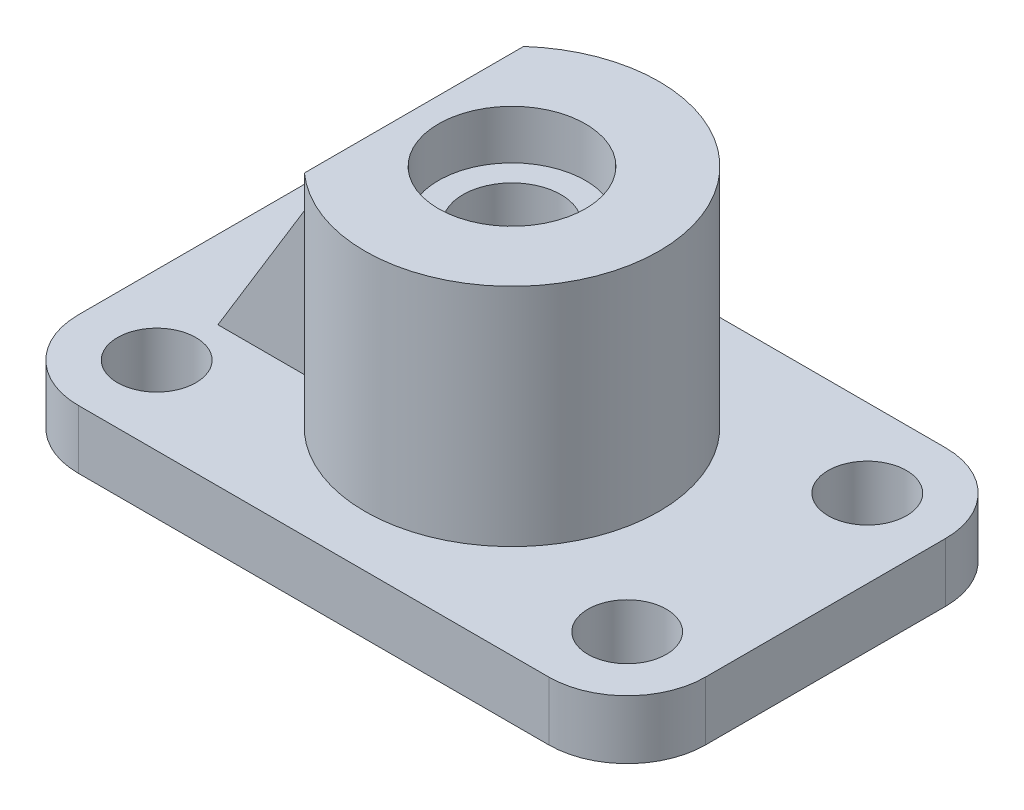
from build123d import *

# Parameters (mm, degrees)
IZIM1_R                     = 8
Y_KSEKLIK_EKSTR_ZYON1_DEPTH = 12
Y_KSEKLIK_EKSTR_ZYON2_DEPTH = 46
IZIM4_R                     = 15
KES_EKSTR_ZYON1_DEPTH       = 10
IZIM5_R                     = 10
KES_EKSTR_ZYON2_DEPTH       = 114.846387734
FEDER7_REACH                = 101.057
IZIM16_WALL_W               = 253.965251844
IZIM16_WALL_H               = 8


with BuildPart() as part:
    # Çizim1 → Yükseklik-Ekstrüzyon1 (new body)
    with BuildSketch(Plane(origin=(0, 0, 0), x_dir=(1, 0, 0), z_dir=(0, 1, 0))):
        with BuildLine():
            Line((48, 0), (-48, 0))
            ThreePointArc((-48, 0), (-59.313708499, 4.686291501), (-64, 16))
            Line((-64, 16), (-64, 49))
            Line((-64, 49), (-64, 65))
            ThreePointArc((-64, 65), (-59.313708499, 76.313708499), (-48, 81))
            Line((-48, 81), (48, 81))
            ThreePointArc((48, 81), (59.313708499, 76.313708499), (64, 65))
            Line((64, 65), (64, 49))
            Line((64, 49), (64, 16))
            ThreePointArc((64, 16), (59.313708499, 4.686291501), (48, 0))
        make_face()
        with Locations(Location((-48, 65, 0), (0, 0, 270))):
            Circle(IZIM1_R, mode=Mode.SUBTRACT)
        with Locations(Location((-48, 16, 0), (0, 0, 270))):
            Circle(IZIM1_R, mode=Mode.SUBTRACT)
        with Locations(Location((48, 65, 0), (0, 0, 270))):
            Circle(IZIM1_R, mode=Mode.SUBTRACT)
        with Locations(Location((48, 16, 0), (0, 0, 270))):
            Circle(IZIM1_R, mode=Mode.SUBTRACT)
    extrude(amount=Y_KSEKLIK_EKSTR_ZYON1_DEPTH)

    # Çizim2 → Yükseklik-Ekstrüzyon2 (add)
    with BuildSketch(Plane(origin=(0, 12, 0), x_dir=(1, 0, 0), z_dir=(0, 1, 0))):
        with BuildLine():
            Line((-20, 62.860679775), (-20, 40.5))
            Line((-20, 40.5), (-20, 18.139320225))
            ThreePointArc((-20, 18.139320225), (30, 40.5), (-20, 62.860679775))
        make_face()
    extrude(amount=Y_KSEKLIK_EKSTR_ZYON2_DEPTH)

    # Çizim4 → Kes-Ekstrüzyon1 (cut)
    with BuildSketch(Plane(origin=(0, 58, 0), x_dir=(1, 0, 0), z_dir=(0, 1, 0))):
        with Locations(Location((0, 40.5, 0), (0, 0, 270))):
            Circle(IZIM4_R)
    extrude(amount=-KES_EKSTR_ZYON1_DEPTH, mode=Mode.SUBTRACT)

    # Çizim5 → Kes-Ekstrüzyon2 (cut, through all)
    with BuildSketch(Plane(origin=(0, 48, 0), x_dir=(1, 0, 0), z_dir=(0, 1, 0))):
        with Locations(Location((0, 40.5, 0), (0, 0, 270))):
            Circle(IZIM5_R)
    extrude(amount=-KES_EKSTR_ZYON2_DEPTH, mode=Mode.SUBTRACT)

    # Çizim16 wall → Feder7 (add, up to next)
    with BuildSketch(Plane(origin=(-34, 35, -32.5), x_dir=(0.519946946896, 0.854198555614, 0), z_dir=(-0.854198555614, 0.519946946896, 0)), mode=Mode.PRIVATE) as feder7_sk1:
        Rectangle(IZIM16_WALL_W, IZIM16_WALL_H)
    feder7_tool1 = extrude(feder7_sk1.sketch, amount=-FEDER7_REACH, mode=Mode.PRIVATE) - part.part
    add(feder7_tool1.solids().sort_by_distance((-34, 35, -32.5))[0])


solid = part.part
